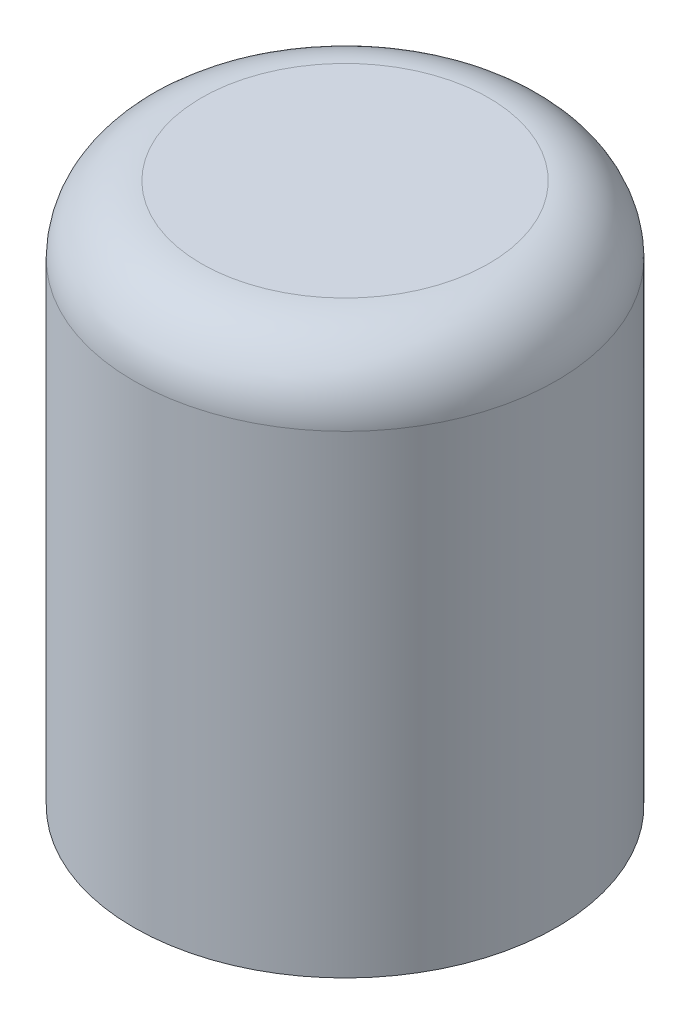
from build123d import *

# Parameters (mm, degrees)
SKETCH1_R           = 3.125
BOSS_EXTRUDE1_DEPTH = 8
SKETCH2_W           = 2.25
SKETCH2_H           = 3.25
CUT_EXTRUDE1_DEPTH  = 3
FILLET1_R           = 1


with BuildPart() as part:
    # Sketch1 → Boss-Extrude1 (new body)
    with BuildSketch(Plane(origin=(0, 0, 0), x_dir=(1, 0, 0), z_dir=(0, 1, 0))):
        Circle(SKETCH1_R)
    extrude(amount=BOSS_EXTRUDE1_DEPTH)

    # Sketch2 → Cut-Extrude1 (cut)
    with BuildSketch(Plane.XZ):
        Rectangle(SKETCH2_W, SKETCH2_H)
    extrude(amount=-CUT_EXTRUDE1_DEPTH, mode=Mode.SUBTRACT)

    # Fillet1
    fillet1_edges = [part.edges().sort_by_distance(p)[0] for p in [
        (-3.125, 8, 0),
    ]]
    fillet(fillet1_edges, radius=FILLET1_R)


solid = part.part
